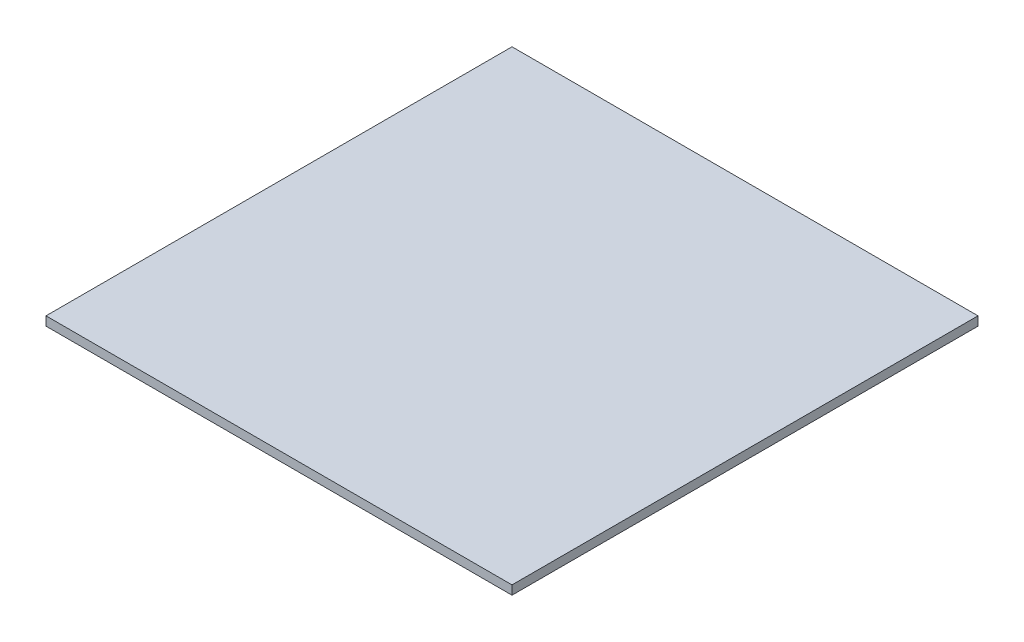
from build123d import *

# Parameters (mm, degrees)
SKETCH2_W           = 130
SKETCH2_H           = 130
BOSS_EXTRUDE1_DEPTH = 2.5


with BuildPart() as part:
    # Sketch2 → Boss-Extrude1 (new body)
    with BuildSketch(Plane(origin=(0, 0, 0), x_dir=(1, 0, 0), z_dir=(0, 1, 0))):
        Rectangle(SKETCH2_W, SKETCH2_H)
    extrude(amount=BOSS_EXTRUDE1_DEPTH)


solid = part.part
